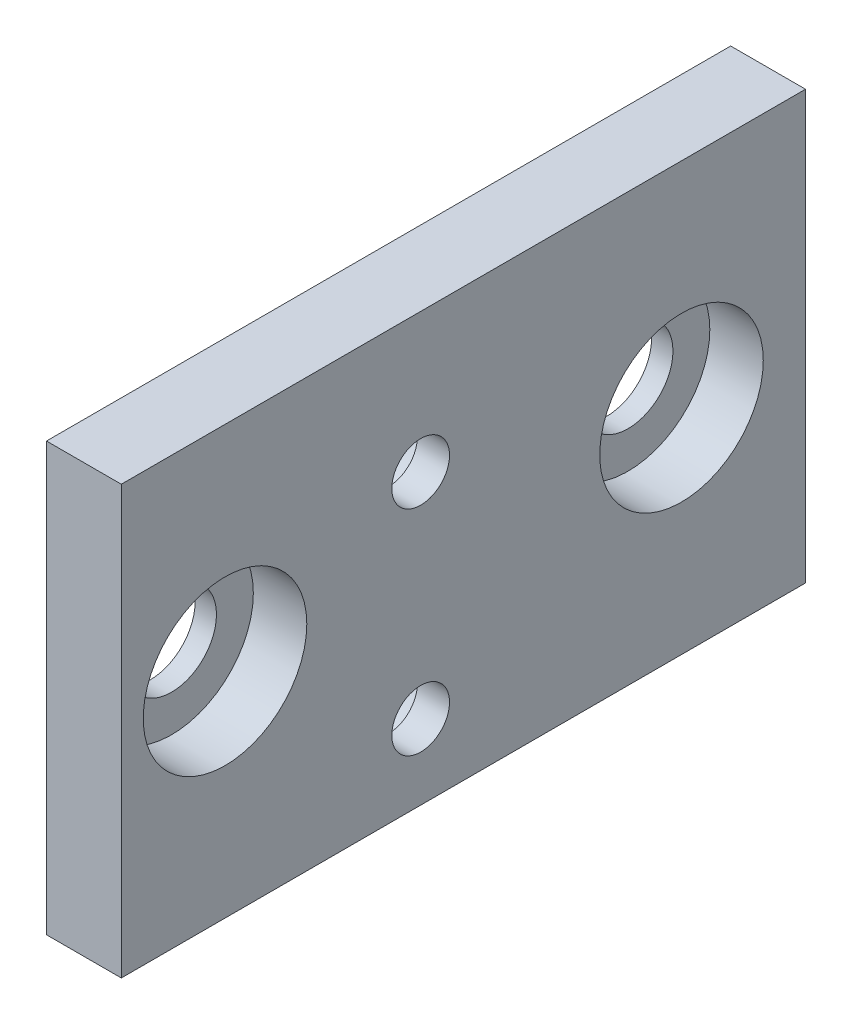
from build123d import *

# Parameters (mm, degrees)
CROQUIS1_W              = 21
CROQUIS1_H              = 20
SALIENTE_EXTRUIR1_DEPTH = 5
CROQUIS2_R              = 1.35
CORTAR_EXTRUIR1_DEPTH   = 6
CROQUIS3_R              = 2.5
CORTAR_EXTRUIR2_DEPTH   = 2
CROQUIS4_R              = 2.1
CORTAR_EXTRUIR3_DEPTH   = 6
CROQUIS5_R              = 3.825
CORTAR_EXTRUIR4_DEPTH   = 4
CROQUIS7_W              = 21
CROQUIS7_H              = 20
CORTAR_EXTRUIR5_DEPTH   = 2
CROQUIS8_W              = 3
CROQUIS8_H              = 20
SALIENTE_EXTRUIR2_DEPTH = 11
CROQUIS9_R              = 2.1
CORTAR_EXTRUIR6_DEPTH   = 4
CROQUIS10_R             = 3.825
CORTAR_EXTRUIR7_DEPTH   = 2
CROQUIS11_W             = 32
CROQUIS11_H             = 20
CROQUIS11_R             = 3.825
CROQUIS11_R_2           = 1.35
SALIENTE_EXTRUIR3_DEPTH = 0.5


with BuildPart() as part:
    # Croquis1 → Saliente-Extruir1 (new body)
    with BuildSketch(Plane(origin=(0, 0, 0), x_dir=(0, 0, -1), z_dir=(1, 0, 0))):
        Rectangle(CROQUIS1_W, CROQUIS1_H)
    extrude(amount=SALIENTE_EXTRUIR1_DEPTH)

    # Croquis2 → Cortar-Extruir1 (cut, through all)
    with BuildSketch(Plane(origin=(5, 0, 0), x_dir=(0, 0, -1), z_dir=(1, 0, 0))):
        with Locations((-7.5, 3.5)):
            Circle(CROQUIS2_R)
        with Locations((-7.5, -6.5)):
            Circle(CROQUIS2_R)
    extrude(amount=-CORTAR_EXTRUIR1_DEPTH, mode=Mode.SUBTRACT)

    # Croquis3 → Cortar-Extruir2 (cut)
    with BuildSketch(Plane.ZY):
        with Locations((7.5, 3.5)):
            Circle(CROQUIS3_R)
        with Locations((7.5, -6.5)):
            Circle(CROQUIS3_R)
    extrude(amount=-CORTAR_EXTRUIR2_DEPTH, mode=Mode.SUBTRACT)

    # Croquis4 → Cortar-Extruir3 (cut, through all)
    with BuildSketch(Plane(origin=(5, 0, 0), x_dir=(0, 0, -1), z_dir=(1, 0, 0))):
        with Locations((4.7, 0)):
            Circle(CROQUIS4_R)
    extrude(amount=-CORTAR_EXTRUIR3_DEPTH, mode=Mode.SUBTRACT)

    # Croquis5 → Cortar-Extruir4 (cut)
    with BuildSketch(Plane(origin=(5, 0, 0), x_dir=(0, 0, -1), z_dir=(1, 0, 0))):
        with Locations((4.7, 0)):
            Circle(CROQUIS5_R)
    extrude(amount=-CORTAR_EXTRUIR4_DEPTH, mode=Mode.SUBTRACT)

    # Croquis7 → Cortar-Extruir5 (cut)
    with BuildSketch(Plane(origin=(5, 0, 0), x_dir=(0, 0, -1), z_dir=(1, 0, 0))):
        Rectangle(CROQUIS7_W, CROQUIS7_H)
    extrude(amount=-CORTAR_EXTRUIR5_DEPTH, mode=Mode.SUBTRACT)

    # Croquis8 → Saliente-Extruir2 (add)
    with BuildSketch(Plane.XY.offset(10.5)):
        with Locations((1.5, 0)):
            Rectangle(CROQUIS8_W, CROQUIS8_H)
    extrude(amount=SALIENTE_EXTRUIR2_DEPTH)

    # Croquis9 → Cortar-Extruir6 (cut, through all)
    with BuildSketch(Plane(origin=(3, 0, 0), x_dir=(0, 0, -1), z_dir=(1, 0, 0))):
        with Locations((-16.65, 0)):
            Circle(CROQUIS9_R)
    extrude(amount=-CORTAR_EXTRUIR6_DEPTH, mode=Mode.SUBTRACT)

    # Croquis10 → Cortar-Extruir7 (cut)
    with BuildSketch(Plane(origin=(3, 0, 0), x_dir=(0, 0, -1), z_dir=(1, 0, 0))):
        with Locations((-16.65, 0)):
            Circle(CROQUIS10_R)
    extrude(amount=-CORTAR_EXTRUIR7_DEPTH, mode=Mode.SUBTRACT)

    # Croquis11 → Saliente-Extruir3 (add)
    with BuildSketch(Plane(origin=(3, 0, 0), x_dir=(0, 0, -1), z_dir=(1, 0, 0))):
        with Locations((-5.5, 0)):
            Rectangle(CROQUIS11_W, CROQUIS11_H)
        with Locations((-16.65, 0)):
            Circle(CROQUIS11_R, mode=Mode.SUBTRACT)
        with Locations((-7.5, 3.5)):
            Circle(CROQUIS11_R_2, mode=Mode.SUBTRACT)
        with Locations((-7.5, -6.5)):
            Circle(CROQUIS11_R_2, mode=Mode.SUBTRACT)
        with Locations((4.7, 0)):
            Circle(CROQUIS11_R, mode=Mode.SUBTRACT)
    extrude(amount=SALIENTE_EXTRUIR3_DEPTH)


solid = part.part
